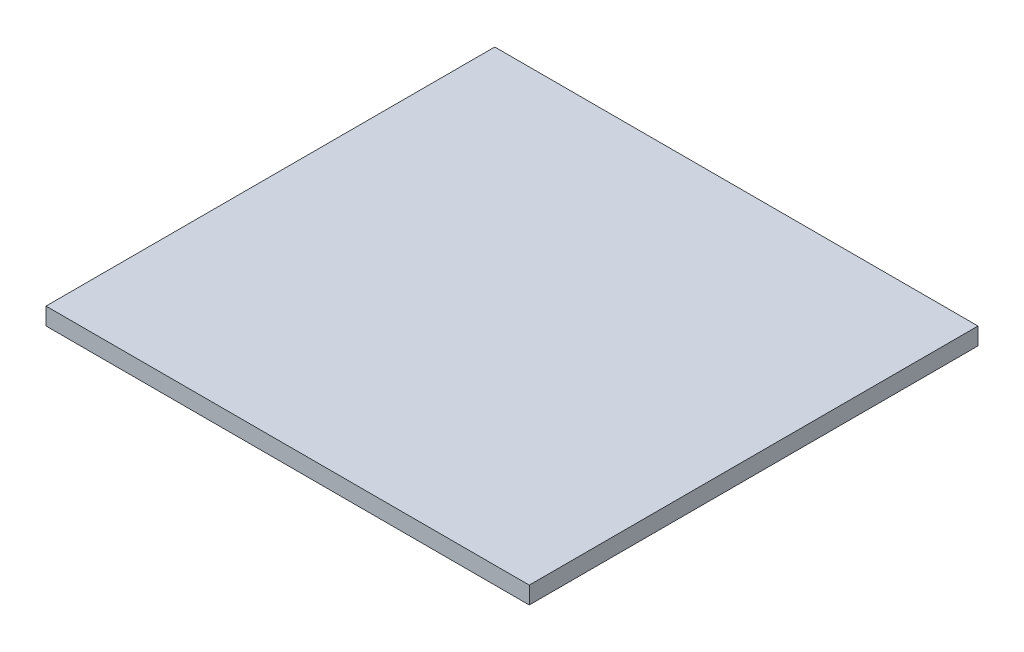
from build123d import *

# Parameters (mm, degrees)
SKETCH1_W           = 140
SKETCH1_H           = 130
BOSS_EXTRUDE1_DEPTH = 5


with BuildPart() as part:
    # Sketch1 → Boss-Extrude1 (new body)
    with BuildSketch(Plane(origin=(0, 0, 0), x_dir=(1, 0, 0), z_dir=(0, 1, 0))):
        with Locations((-7.304347826, -21.326086957)):
            Rectangle(SKETCH1_W, SKETCH1_H)
    extrude(amount=BOSS_EXTRUDE1_DEPTH)


solid = part.part
